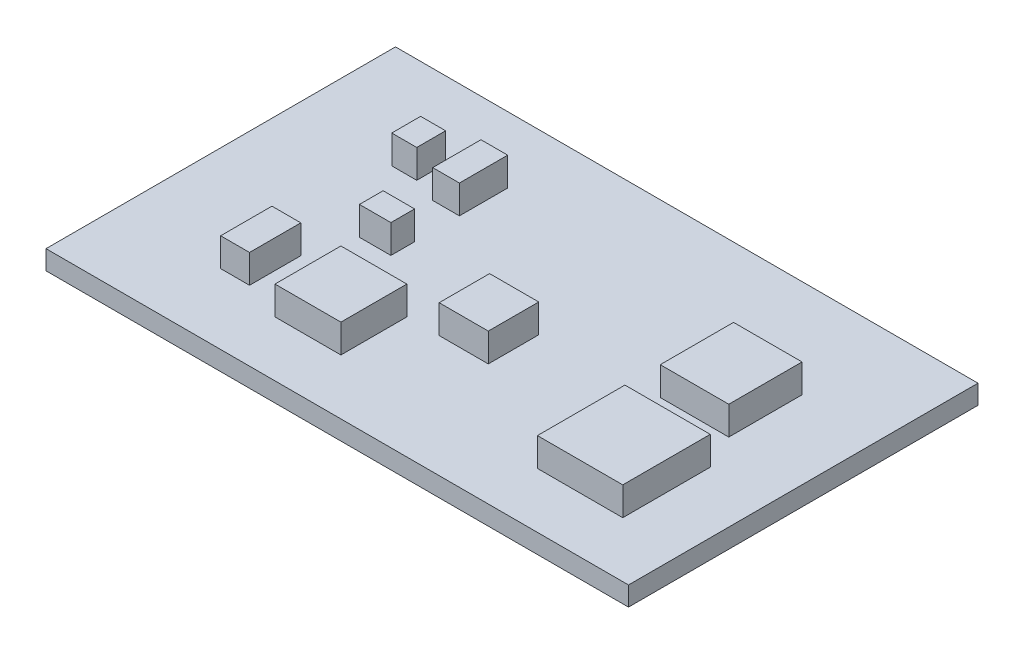
from build123d import *

# Parameters (mm, degrees)
SKETCH1_W           = 32.75
SKETCH1_H           = 19.65
BOSS_EXTRUDE1_DEPTH = 1.08
SKETCH2_W           = 1.405419427
SKETCH2_H           = 1.623501752
SKETCH2_W_2         = 1.502344905
SKETCH2_H_2         = 2.713913376
SKETCH2_W_3         = 1.623501751
SKETCH2_H_3         = 2.883532962
SKETCH2_W_4         = 3.707399523
SKETCH2_H_4         = 3.707399523
SKETCH2_W_5         = 2.762376115
SKETCH2_H_5         = 2.835070223
SKETCH2_W_6         = 4.797811147
SKETCH2_H_6         = 4.918967994
SKETCH2_W_7         = 3.852787739
SKETCH2_H_7         = 4.119332803
SKETCH2_W_8         = 1.768889968
SKETCH2_H_8         = 1.332725318
BOSS_EXTRUDE2_DEPTH = 1.6
SKETCH3_W           = 6.809014809
SKETCH3_H           = 6.978634395
SKETCH3_W_2         = 3.198540765
SKETCH3_H_2         = 1.405419426
SKETCH3_W_3         = 2.786607484
SKETCH3_W_4         = 3.077383918
SKETCH3_H_3         = 1.478113535
SKETCH3_W_5         = 3.125846656
BOSS_EXTRUDE3_DEPTH = 1.45


with BuildPart() as part:
    # Sketch1 → Boss-Extrude1 (new body)
    with BuildSketch(Plane(origin=(0, 0, 0), x_dir=(1, 0, 0), z_dir=(0, 1, 0))):
        Rectangle(SKETCH1_W, SKETCH1_H)
    extrude(amount=BOSS_EXTRUDE1_DEPTH)

    # Sketch2 → Boss-Extrude2 (add)
    with BuildSketch(Plane(origin=(0, 1.08, 0), x_dir=(1, 0, 0), z_dir=(0, 1, 0))):
        with Locations((-9.983324205, 4.737232723)):
            Rectangle(SKETCH2_W, SKETCH2_H)
        with Locations((-7.099791243, 4.749348408)):
            Rectangle(SKETCH2_W_2, SKETCH2_H_2)
        with Locations((-9.680432087, -4.44645629)):
            Rectangle(SKETCH2_W_3, SKETCH2_H_3)
        with Locations((-4.761464093, -4.85838957)):
            Rectangle(SKETCH2_W_4, SKETCH2_H_4)
        with Locations((0.290776433, -1.587154698)):
            Rectangle(SKETCH2_W_5, SKETCH2_H_5)
        with Locations((10.540645702, -4.252605335)):
            Rectangle(SKETCH2_W_6, SKETCH2_H_6)
        with Locations((10.068133998, 2.253517357)):
            Rectangle(SKETCH2_W_7, SKETCH2_H_7)
        with Locations((-7.233063774, 0.20596664)):
            Rectangle(SKETCH2_W_8, SKETCH2_H_8)
    extrude(amount=BOSS_EXTRUDE2_DEPTH)

    # Sketch3 → Boss-Extrude3 (add)
    with BuildSketch(Plane.XZ):
        with Locations((-0.860213615, 0.920792039)):
            Rectangle(SKETCH3_W, SKETCH3_H)
        with Locations((-11.049504459, -4.918967994)):
            Rectangle(SKETCH3_W_2, SKETCH3_H_2)
        with Locations((-7.596534316, -4.918967994)):
            Rectangle(SKETCH3_W_3, SKETCH3_H_2)
        with Locations((-8.178087182, 5.415711068)):
            Rectangle(SKETCH3_W_4, SKETCH3_H_3)
        with Locations((-11.691635749, 5.415711068)):
            Rectangle(SKETCH3_W_5, SKETCH3_H_3)
    extrude(amount=BOSS_EXTRUDE3_DEPTH)


solid = part.part
